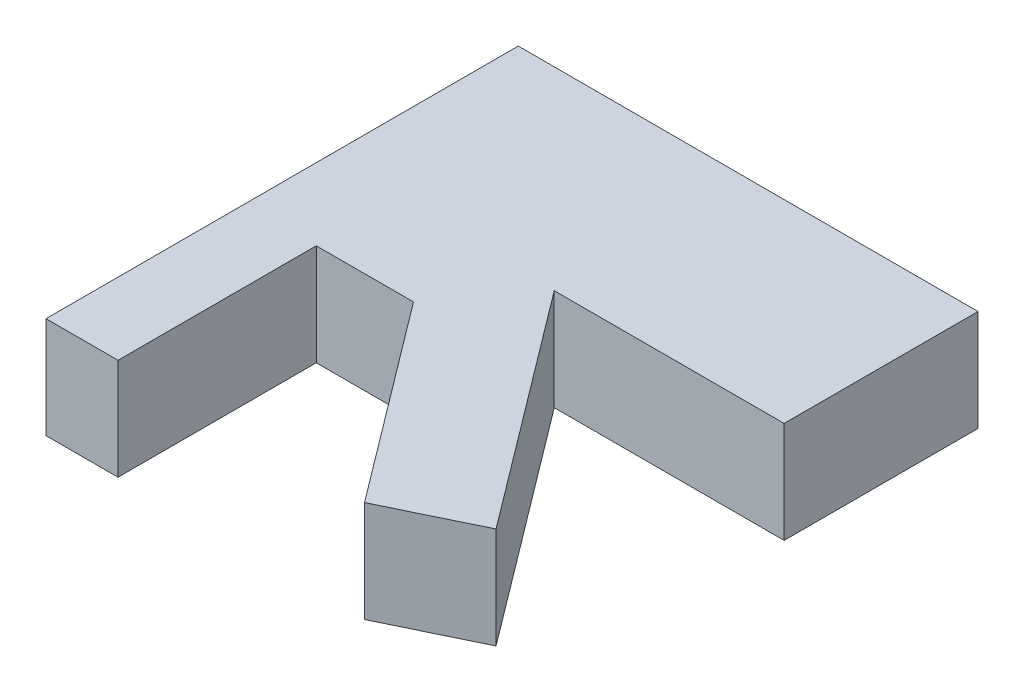
from build123d import *

# Parameters (mm, degrees)
BOSS_EXTRUDE1_DEPTH = 10


with BuildPart() as part:
    # Sketch1 → Boss-Extrude1 (new body)
    with BuildSketch(Plane(origin=(0, 0, 0), x_dir=(1, 0, 0), z_dir=(0, 1, 0))):
        Polygon((0, 0), (0, 46.608092397), (45.377966791, 46.608092397), (45.377966791, 27.472805196), (22.688983396, 27.472805196), (40.184103122, 4.237099309), (31.436543259, 0), (16.70377019, 19.566964232), (7.107392389, 19.566964232), (7.107392389, 0), align=None)
    extrude(amount=BOSS_EXTRUDE1_DEPTH)


solid = part.part
